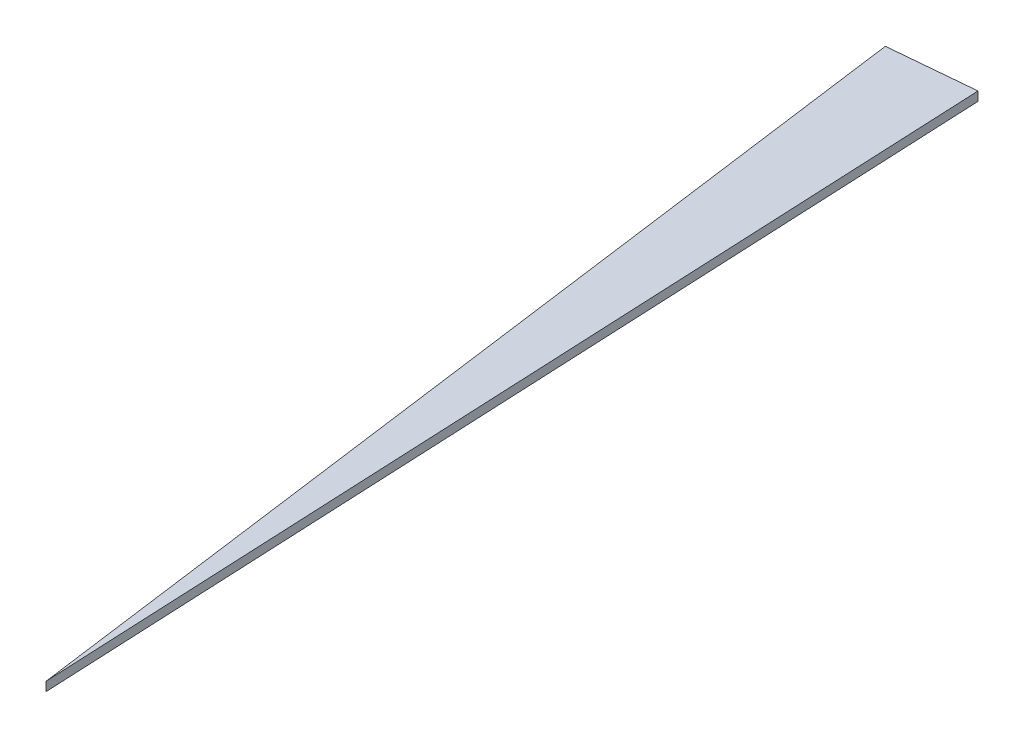
from build123d import *

# Parameters (mm, degrees)
BOSS_EXTRUDE1_DEPTH = 0.6


with BuildPart() as part:
    # Sketch1 → Boss-Extrude1 (new body)
    with BuildSketch(Plane(origin=(0, 0, 0), x_dir=(1, 0, 0), z_dir=(0, 1, 0))):
        Polygon((0, 0), (-8.653618916, 64.421385266), (-3.005995602, 64.93045503), align=None)
    extrude(amount=BOSS_EXTRUDE1_DEPTH)


solid = part.part
